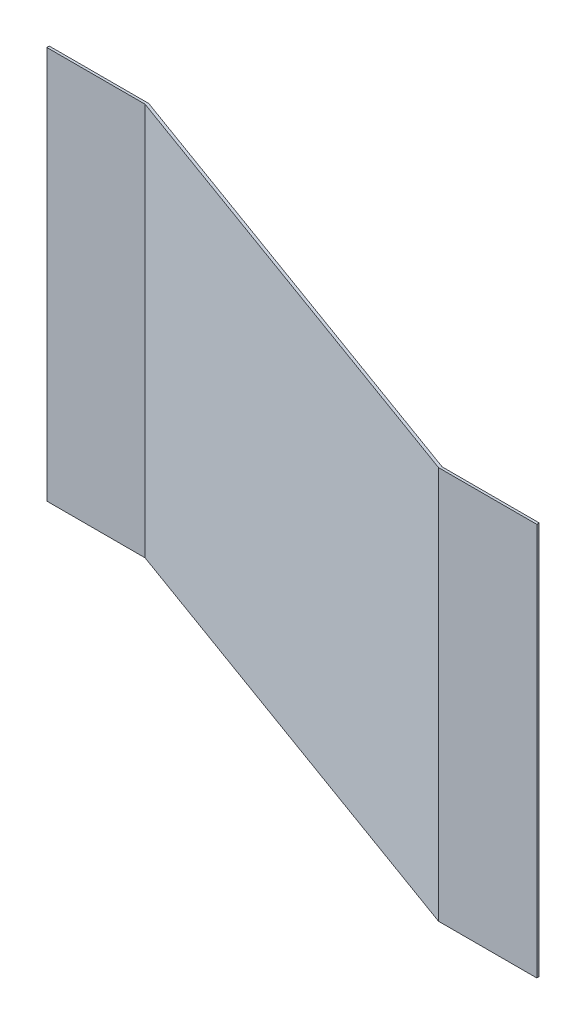
from build123d import *

# Parameters (mm, degrees)
BOSS_EXTRUDE1_DEPTH = 40000


with BuildPart() as part:
    # Sketch1 → Boss-Extrude1 (new body)
    with BuildSketch(Plane(origin=(0, 0, 0), x_dir=(1, 0, 0), z_dir=(0, 1, 0))):
        Polygon((0, 0), (46983.398055274, -17104.394382136), (56862.657077775, -17104.394382136), (56862.657077775, -17354.394382136), (46862.657077775, -17354.394382136), (-120.7409775, -250), (-131.3319775, -250), (-10131.3319775, -250), (-10131.3319775, 0), (-131.3319775, 0), align=None)
    extrude(amount=BOSS_EXTRUDE1_DEPTH)


solid = part.part
